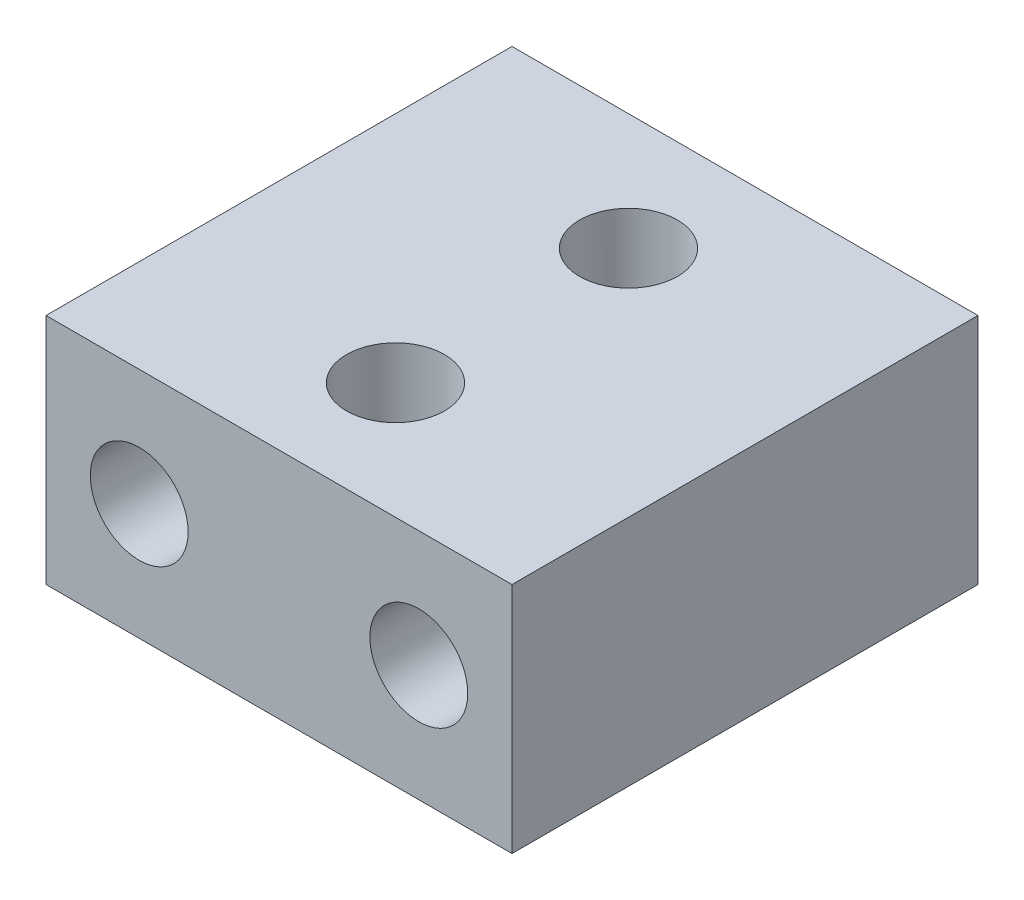
from build123d import *

# Parameters (mm, degrees)
SKETCH1_W           = 20
SKETCH1_H           = 10
SKETCH1_R           = 2.1
BOSS_EXTRUDE1_DEPTH = 20
SKETCH2_R           = 2.1
CUT_EXTRUDE1_DEPTH  = 30


with BuildPart() as part:
    # Sketch1 → Boss-Extrude1 (new body)
    with BuildSketch(Plane.XY):
        with Locations((10, 5)):
            Rectangle(SKETCH1_W, SKETCH1_H)
        with Locations((4, 5)):
            Circle(SKETCH1_R, mode=Mode.SUBTRACT)
        with Locations((16, 5)):
            Circle(SKETCH1_R, mode=Mode.SUBTRACT)
    extrude(amount=BOSS_EXTRUDE1_DEPTH)

    # Sketch2 → Cut-Extrude1 (cut)
    with BuildSketch(Plane.XZ):
        with Locations((10, 15)):
            Circle(SKETCH2_R)
        with Locations((10, 5)):
            Circle(SKETCH2_R)
    extrude(amount=-CUT_EXTRUDE1_DEPTH, mode=Mode.SUBTRACT)


solid = part.part
